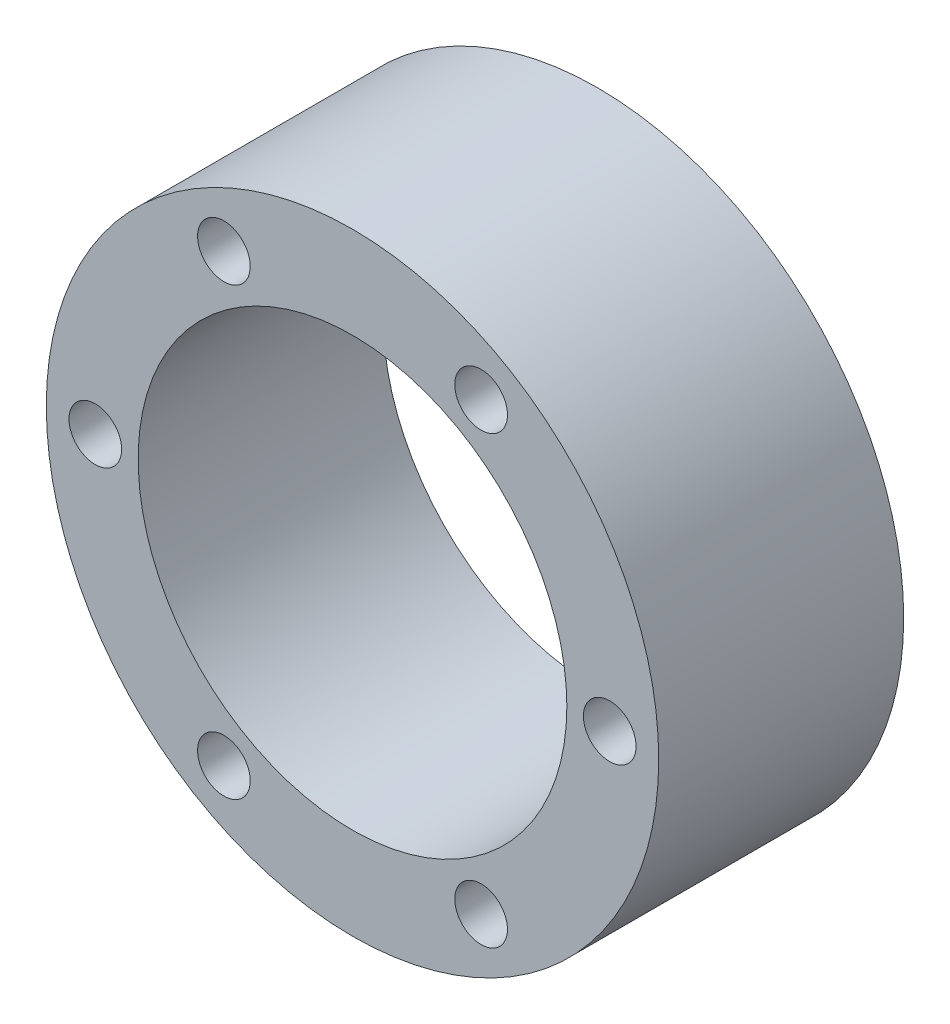
from build123d import *

# Parameters (mm, degrees)
CROQUIS1_R                   = 25
CROQUIS1_R_2                 = 17.5
SALIENTE_EXTRUIR1_DEPTH      = 20
TALADRO_DE_MARGEN_PARA_M41_D = 4.3


with BuildPart() as part:
    # Croquis1 → Saliente-Extruir1 (new body)
    with BuildSketch(Plane.XY):
        Circle(CROQUIS1_R)
        Circle(CROQUIS1_R_2, mode=Mode.SUBTRACT)
    extrude(amount=SALIENTE_EXTRUIR1_DEPTH)

    # Taladro de margen para M41 (through all)
    with Locations(Plane.XY.offset(20)):
        with Locations((21, 0), (10.5, -18.186533479), (-10.5, -18.186533479), (-21, 0), (-10.5, 18.186533479), (10.5, 18.186533479)):
            Hole(TALADRO_DE_MARGEN_PARA_M41_D / 2)


solid = part.part
